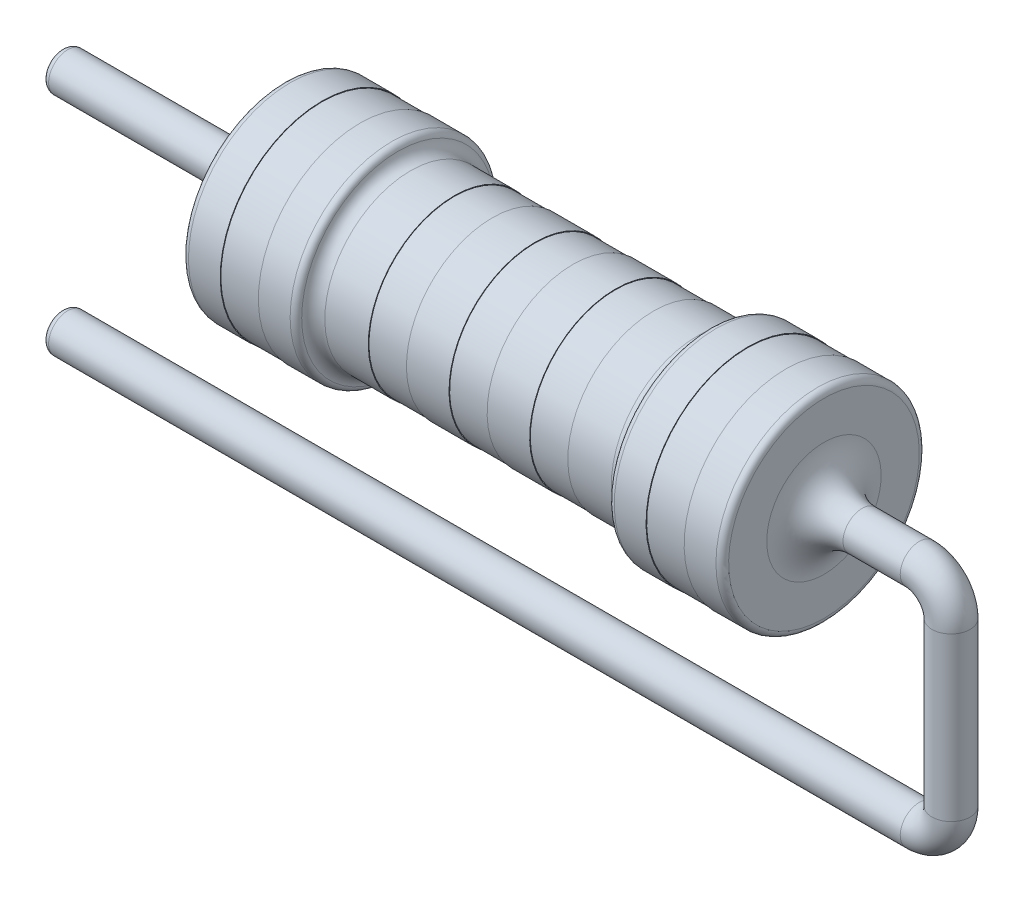
from build123d import *

# Parameters (mm, degrees)
FILLET10_R = 0.1
FILLET11_R = 0.2
SKETCH3_R  = 0.3
SKETCH4_R  = 0.3
FILLET12_R = 0.1
FILLET13_R = 0.6


with BuildPart() as part:
    # Sketch1 → Revolve2 (revolve)
    with BuildSketch(Plane.XY):
        Polygon((4.25, 0), (-4.25, 0), (-4.25, -1.6), (-3.65, -1.6), (-3.65, -1.59), (-3.05, -1.59), (-3.05, -1.6), (-2.45, -1.6), (-2.45, -1.35), (-1.569520407, -1.35), (-1.569520407, -1.34), (-0.969520407, -1.34), (-0.969520407, -1.35), (-0.3, -1.35), (-0.3, -1.34), (0.3, -1.34), (0.3, -1.35), (0.969520407, -1.35), (0.969520407, -1.34), (1.569520407, -1.34), (1.569520407, -1.35), (2.45, -1.35), (2.45, -1.6), (3.05, -1.6), (3.05, -1.59), (3.65, -1.59), (3.65, -1.6), (4.25, -1.6), align=None)
    revolve(axis=Axis((4.25, 0, 0), (-1, 0, 0)))

    # Fillet10
    fillet10_edges = [part.edges().sort_by_distance(p)[0] for p in [
        (2.45, 1.6, 0),
        (4.25, 1.6, 0),
        (-4.25, 1.6, 0),
        (-2.45, 1.6, 0),
    ]]
    fillet(fillet10_edges, radius=FILLET10_R)

    # Fillet11
    fillet11_edges = [part.edges().sort_by_distance(p)[0] for p in [
        (2.45, 1.35, 0),
        (-2.45, 1.35, 0),
    ]]
    fillet(fillet11_edges, radius=FILLET11_R)

    # Sweep1: sweep along a curve in space
    with BuildLine() as sweep1_path:
        Line((4.25, 0, 0), (5.75, 0, 0))
        ThreePointArc((6.25, -0.5, 0), (6.103553391, -0.146446609, 0), (5.75, 0, 0))
        Line((6.25, -0.5, 0), (6.25, -3.05666344, 0))
        ThreePointArc((5.75, -3.55666344, 0), (6.103553391, -3.410216831, 0), (6.25, -3.05666344, 0))
        Line((5.75, -3.55666344, 0), (-7.75, -3.55666344, 0))
    # Sketch3 → Sweep1 (sweep)
    with BuildSketch(Plane(origin=(4.25, 0, 0), x_dir=(0, 0, -1), z_dir=(1, 0, 0))):
        Circle(SKETCH3_R)
    sweep(path=sweep1_path.line)

    # Sweep2: sweep along a curve in space
    with BuildLine() as sweep2_path:
        Line((-4.25, 0, 0), (-7.75, 0, 0))
    # Sketch4 → Sweep2 (sweep)
    with BuildSketch(Plane.ZY.offset(4.25)):
        Circle(SKETCH4_R)
    sweep(path=sweep2_path.line)

    # Fillet12
    fillet12_edges = [part.edges().sort_by_distance(p)[0] for p in [
        (-7.75, -3.55666344, 0.3),
        (-7.75, 0, -0.3),
    ]]
    fillet(fillet12_edges, radius=FILLET12_R)

    # Fillet13
    fillet13_edges = [part.edges().sort_by_distance(p)[0] for p in [
        (4.25, 0, 0.3),
        (-4.25, 0, -0.3),
    ]]
    fillet(fillet13_edges, radius=FILLET13_R)


solid = part.part
